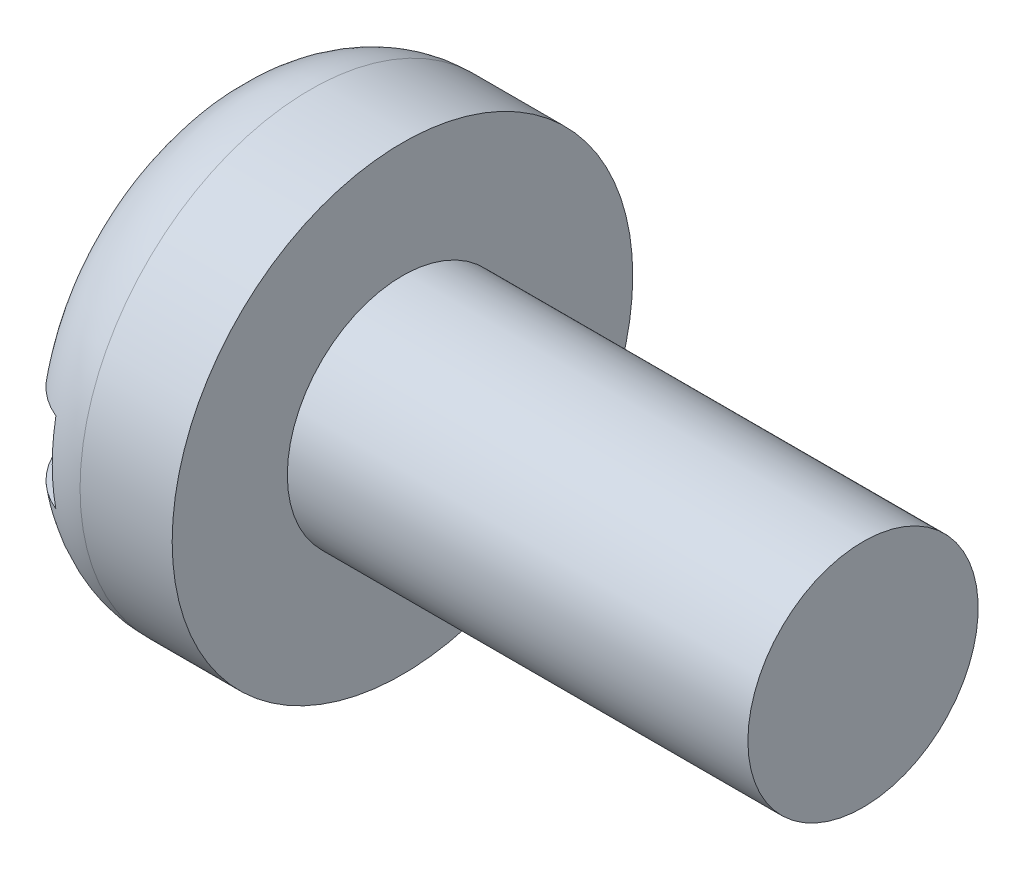
from build123d import *

# Parameters (mm, degrees)
SKETCH2_W  = 4
SKETCH2_H  = 0.7
SLOT_DEPTH = 0.5


with BuildPart() as part:
    # BodySke → Base-Revolve (revolve)
    with BuildSketch(Plane.XY):
        with BuildLine():
            Line((1.6, 1), (1.6, 2))
            Line((1.6, 2), (0.8, 2))
            ThreePointArc((0.8, 2), (0.234314575, 1.765685425), (0, 1.2))
            Line((0, 1.2), (0, 0))
            Line((0, 0), (5.6, 0))
            Line((5.6, 0), (5.6, 1))
            Line((5.6, 1), (1.6, 1))
        make_face()
    revolve(axis=Axis((-25.4, 0, 0), (1, 0, 0)))

    # Sketch2 → Slot (cut)
    with BuildSketch(Plane(origin=(0, 0, 0), x_dir=(0, 0, -1), z_dir=(1, 0, 0))):
        Rectangle(SKETCH2_W, SKETCH2_H)
    extrude(amount=SLOT_DEPTH, mode=Mode.SUBTRACT)


solid = part.part
